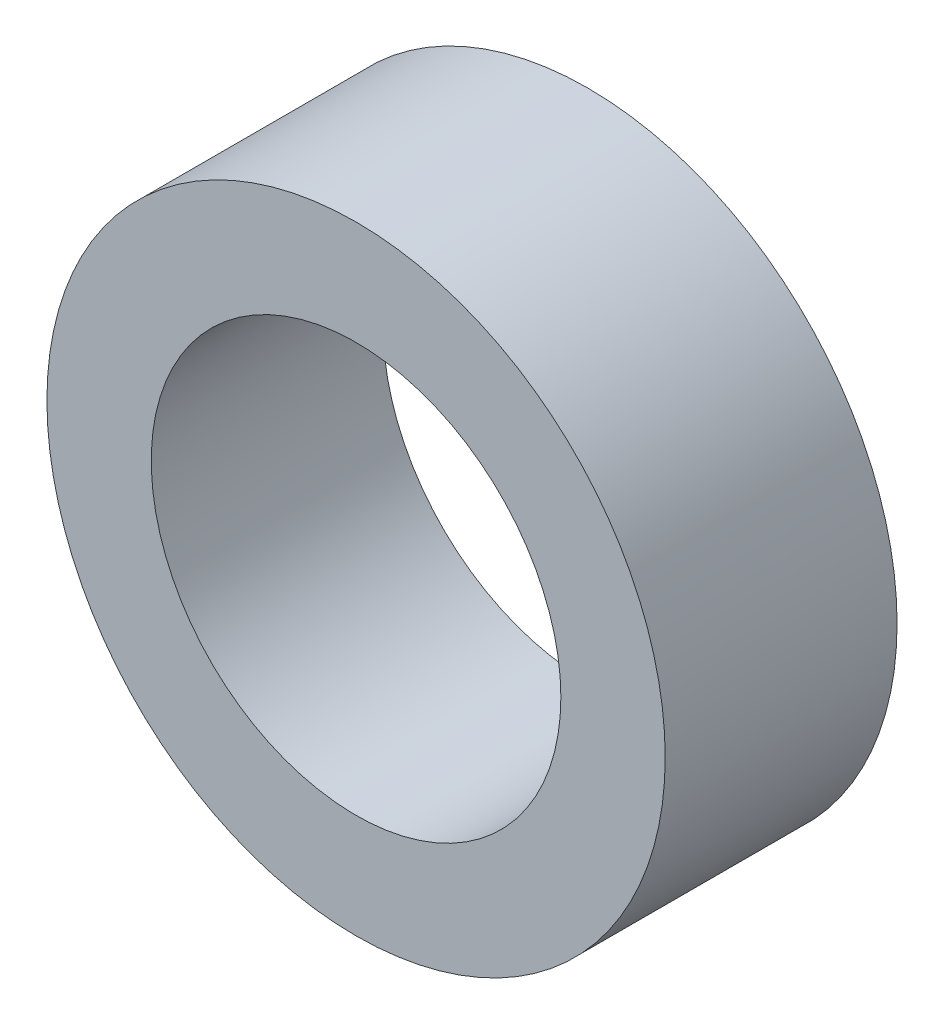
from build123d import *

# Parameters (mm, degrees)
SKETCH1_R           = 4
SKETCH1_R_2         = 2.65
EXTRUDE1_DEPTH      = 1.5
EXTRUDE1_DEPTH_BACK = 1.5


with BuildPart() as part:
    # Sketch1 → Extrude1 (new body, two sides)
    with BuildSketch(Plane.XY) as extrude1_sk:
        Circle(SKETCH1_R)
        Circle(SKETCH1_R_2, mode=Mode.SUBTRACT)
    extrude(amount=EXTRUDE1_DEPTH)
    extrude(extrude1_sk.sketch, amount=-EXTRUDE1_DEPTH_BACK)


solid = part.part
